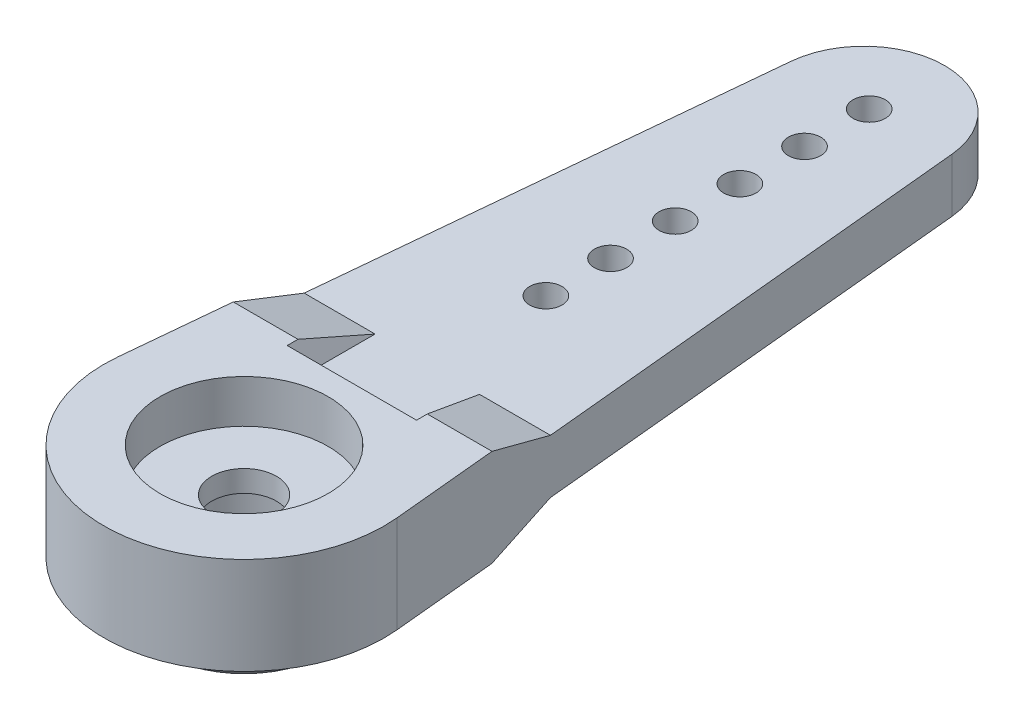
from build123d import *

# Parameters (mm, degrees)
SKETCH1_R           = 0.75
BOSS_EXTRUDE1_DEPTH = 2.25
CUT_EXTRUDE1_DEPTH  = 7
SKETCH3_W           = 6
SKETCH3_H           = 3.5
CUT_EXTRUDE2_DEPTH  = 1
DRAFT1_ANGLE        = 30
DRAFT2_ANGLE        = 30
SKETCH4_R           = 3.9
CUT_EXTRUDE3_DEPTH  = 2
SKETCH5_R           = 4.8
BOSS_EXTRUDE2_DEPTH = 2
CHAMFER1_SIZE       = 1
SKETCH6_R           = 3
CUT_EXTRUDE4_DEPTH  = 3.5
SKETCH7_R           = 1.5
CUT_EXTRUDE5_DEPTH  = 4


with BuildPart() as part:
    # Sketch1 → Boss-Extrude1 (new body, symmetric)
    with BuildSketch(Plane(origin=(0, 0, 0), x_dir=(1, 0, 0), z_dir=(0, 1, 0))):
        with BuildLine():
            Line((-6.470196323, 0.62173913), (-3.732805571, 29.108695652))
            ThreePointArc((-3.732805571, 29.108695652), (0, 32.5), (3.732805571, 29.108695652))
            Line((3.732805571, 29.108695652), (6.470196323, 0.62173913))
            ThreePointArc((6.470196323, 0.62173913), (0, -6.5), (-6.470196323, 0.62173913))
        make_face()
        with Locations((0, 29)):
            Circle(SKETCH1_R, mode=Mode.SUBTRACT)
        with Locations((0, 26)):
            Circle(SKETCH1_R, mode=Mode.SUBTRACT)
        with Locations((0, 23)):
            Circle(SKETCH1_R, mode=Mode.SUBTRACT)
        with Locations((0, 20)):
            Circle(SKETCH1_R, mode=Mode.SUBTRACT)
        with Locations((0, 17)):
            Circle(SKETCH1_R, mode=Mode.SUBTRACT)
        with Locations((0, 14)):
            Circle(SKETCH1_R, mode=Mode.SUBTRACT)
    extrude(amount=BOSS_EXTRUDE1_DEPTH, both=True)

    # Sketch2 → Cut-Extrude1 (cut, symmetric)
    with BuildSketch(Plane(origin=(0, 0, 0), x_dir=(0, 0, -1), z_dir=(1, 0, 0))):
        Polygon((5.5, 2.25), (32.5, 2.25), (32.5, 1.25), (8.5, 1.25), align=None)
    cut_extrude1 = extrude(amount=CUT_EXTRUDE1_DEPTH, both=True, mode=Mode.SUBTRACT)

    # Sketch3 → Cut-Extrude2 (cut)
    with BuildSketch(Plane(origin=(0, 2.25, 0), x_dir=(1, 0, 0), z_dir=(0, 1, 0))):
        with Locations((0, 6.75)):
            Rectangle(SKETCH3_W, SKETCH3_H)
    cut_extrude2 = extrude(amount=-CUT_EXTRUDE2_DEPTH, mode=Mode.SUBTRACT)

    # Mirror1: Cut-Extrude1, Cut-Extrude2 across plane
    add(cut_extrude1.mirror(Plane.ZX), mode=Mode.SUBTRACT)
    add(cut_extrude2.mirror(Plane.ZX), mode=Mode.SUBTRACT)

    # Draft1
    draft1_faces = [part.faces().sort_by_distance(p)[0] for p in [
        (0, 1.75, -5),
        (-3, 1.625, -6.1875),
        (3, 1.625, -6.1875),
    ]]
    draft(draft1_faces, Plane.ZX.offset(2.25), DRAFT1_ANGLE)

    # Draft2
    draft2_faces = [part.faces().sort_by_distance(p)[0] for p in [
        (-3, -1.625, -6.1875),
        (0, -1.75, -5),
        (3, -1.625, -6.1875),
    ]]
    draft(draft2_faces, Plane(origin=(0, -2.25, 0), x_dir=(0, 0, -1), z_dir=(0, -1, 0)), DRAFT2_ANGLE)

    # Sketch4 → Cut-Extrude3 (cut)
    with BuildSketch(Plane(origin=(0, 2.25, 0), x_dir=(1, 0, 0), z_dir=(0, 1, 0))):
        Circle(SKETCH4_R)
    extrude(amount=-CUT_EXTRUDE3_DEPTH, mode=Mode.SUBTRACT)

    # Sketch5 → Boss-Extrude2 (add)
    with BuildSketch(Plane.XZ.offset(2.25)):
        Circle(SKETCH5_R)
    extrude(amount=BOSS_EXTRUDE2_DEPTH)

    # Chamfer1
    chamfer1_edges = [part.edges().sort_by_distance(p)[0] for p in [
        (-4.8, -4.25, 0),
    ]]
    chamfer(chamfer1_edges, length=CHAMFER1_SIZE)

    # Sketch6 → Cut-Extrude4 (cut)
    with BuildSketch(Plane.XZ.offset(4.25)):
        Circle(SKETCH6_R)
    extrude(amount=-CUT_EXTRUDE4_DEPTH, mode=Mode.SUBTRACT)

    # Sketch7 → Cut-Extrude5 (cut, through all)
    with BuildSketch(Plane.XZ.offset(0.75)):
        Circle(SKETCH7_R)
    extrude(amount=-CUT_EXTRUDE5_DEPTH, mode=Mode.SUBTRACT)


solid = part.part
